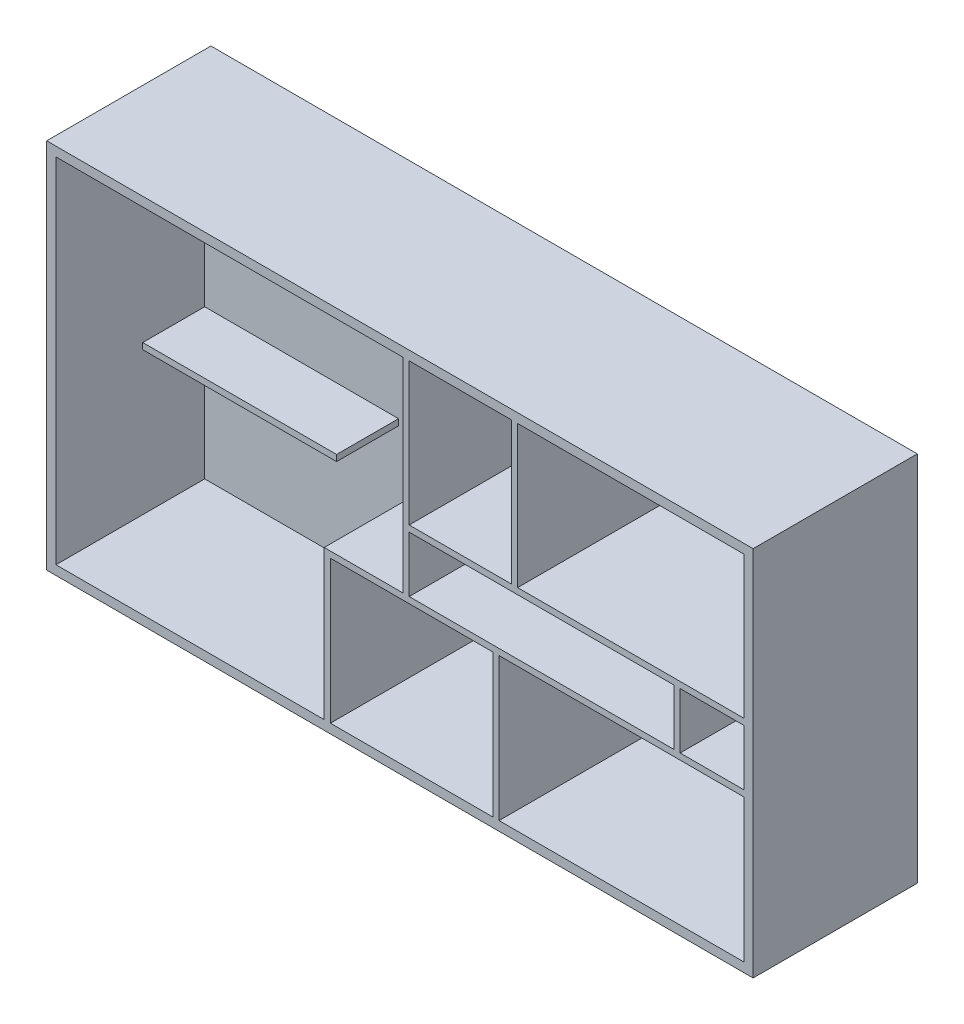
from build123d import *

# Parameters (mm, degrees)
SKETCH3_W           = 11582.4
SKETCH3_H           = 6096
SKETCH3_W_2         = 4341.154286856
SKETCH3_H_2         = 914.4
SKETCH3_W_3         = 1676.4
SKETCH3_H_3         = 2330.801356814
SKETCH3_W_4         = 2663.595025017
SKETCH3_H_4         = 2342.798643186
SKETCH3_W_5         = 1043.645713144
SKETCH3_W_6         = 4013.2
SKETCH3_W_7         = 3708.4
BOSS_EXTRUDE1_DEPTH = 2438.4
SKETCH4_W           = 11582.4
SKETCH4_H           = 6096
BOSS_EXTRUDE2_DEPTH = 254
SKETCH5_W           = 3178.404974983
SKETCH5_H           = 101.6
BOSS_EXTRUDE3_DEPTH = 1016


with BuildPart() as part:
    # Sketch3 → Boss-Extrude1 (new body)
    with BuildSketch(Plane.XY):
        with Locations((5791.2, 3048)):
            Rectangle(SKETCH3_W, SKETCH3_H)
        Polygon((152.4, 152.4), (4550.004974983, 152.4), (4550.004974983, 2596.798643186), (5842, 2596.798643186), (5842, 3511.198643186), (5842, 5943.6), (152.4, 5943.6), align=None, mode=Mode.SUBTRACT)
        with Locations((8114.177143428, 3053.998643186)):
            Rectangle(SKETCH3_W_2, SKETCH3_H_2, mode=Mode.SUBTRACT)
        with Locations((6781.8, 4778.199321593)):
            Rectangle(SKETCH3_W_3, SKETCH3_H_3, mode=Mode.SUBTRACT)
        with Locations((5983.402487492, 1323.799321593)):
            Rectangle(SKETCH3_W_4, SKETCH3_H_4, mode=Mode.SUBTRACT)
        with Locations((10908.177143428, 3053.998643186)):
            Rectangle(SKETCH3_W_5, SKETCH3_H_2, mode=Mode.SUBTRACT)
        with Locations((9423.4, 1323.799321593)):
            Rectangle(SKETCH3_W_6, SKETCH3_H_4, mode=Mode.SUBTRACT)
        with Locations((9575.8, 4778.199321593)):
            Rectangle(SKETCH3_W_7, SKETCH3_H_3, mode=Mode.SUBTRACT)
    extrude(amount=BOSS_EXTRUDE1_DEPTH)

    # Sketch4 → Boss-Extrude2 (add)
    with BuildSketch(Plane(origin=(0, 0, 0), x_dir=(-1, 0, 0), z_dir=(0, 0, -1))):
        with Locations((-5791.2, 3048)):
            Rectangle(SKETCH4_W, SKETCH4_H)
    extrude(amount=BOSS_EXTRUDE2_DEPTH)

    # Sketch5 → Boss-Extrude3 (add)
    with BuildSketch(Plane.XY):
        with Locations((1741.602487492, 2545.998643186)):
            Rectangle(SKETCH5_W, SKETCH5_H)
    extrude(amount=BOSS_EXTRUDE3_DEPTH)


solid = part.part
